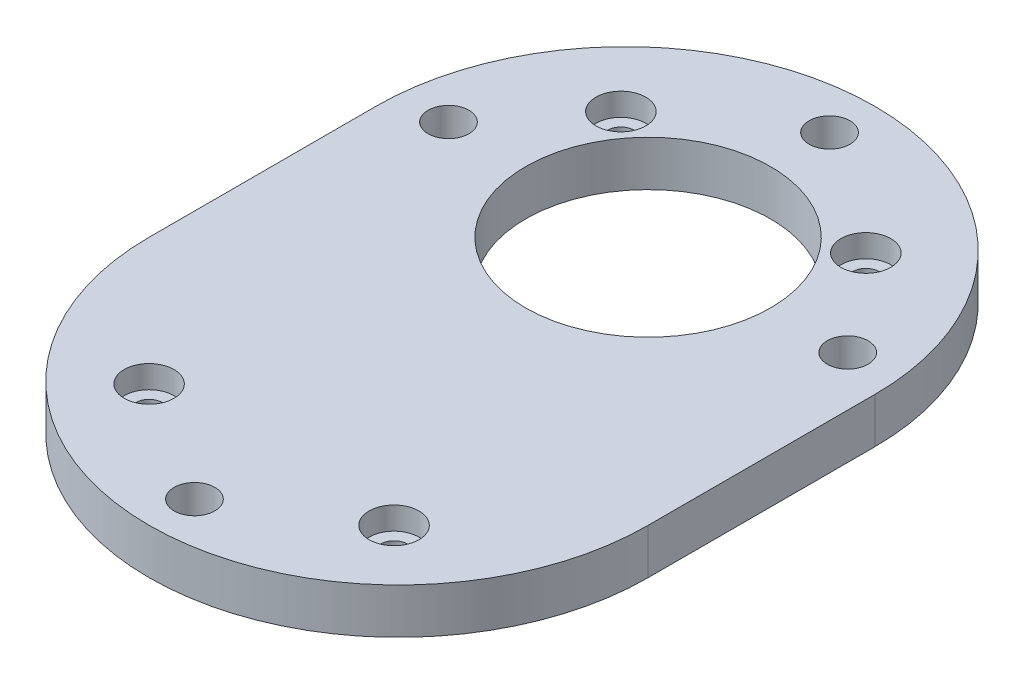
from build123d import *

# Parameters (mm, degrees)
EXTRUDE_1_DEPTH                = 5
SKETCH_2_R                     = 13.5
CUT_EXTRUDE_1_DEPTH            = 5
SKETCH_4_R                     = 2.25
CUT_EXTRUDE_2_DEPTH            = 5
HOLE_WIZARD_M2_5_1_D           = 2.9
HOLE_WIZARD_M2_5_1_CBORE_D     = 5.5
HOLE_WIZARD_M2_5_1_CBORE_DEPTH = 2.5


with BuildPart() as part:
    # 스케치1 → 보스-돌출1 (new body)
    with BuildSketch(Plane(origin=(0, 0, 0), x_dir=(1, 0, 0), z_dir=(0, 1, 0))):
        with BuildLine():
            Line((-27.5, 15), (-27.5, -10))
            ThreePointArc((-27.5, -10), (0, -37.5), (27.5, -10))
            Line((27.5, -10), (27.5, 15))
            ThreePointArc((27.5, 15), (0, 42.5), (-27.5, 15))
        make_face()
    extrude(amount=EXTRUDE_1_DEPTH)

    # 스케치2 → 컷-돌출1 (cut)
    with BuildSketch(Plane(origin=(0, 5, 0), x_dir=(1, 0, 0), z_dir=(0, 1, 0))):
        with Locations((0, 17.5)):
            Circle(SKETCH_2_R)
    extrude(amount=-CUT_EXTRUDE_1_DEPTH, mode=Mode.SUBTRACT)

    # 스케치4 → 컷-돌출2 (cut)
    with BuildSketch(Plane(origin=(0, 5, 0), x_dir=(1, 0, 0), z_dir=(0, 1, 0))):
        with Locations((0, 37.5)):
            Circle(SKETCH_4_R)
        with Locations((0, -32.5)):
            Circle(SKETCH_4_R)
        with Locations((-22, 17.5)):
            Circle(SKETCH_4_R)
        with Locations((22, 17.5)):
            Circle(SKETCH_4_R)
    extrude(amount=-CUT_EXTRUDE_2_DEPTH, mode=Mode.SUBTRACT)

    # M2.5 소켓 머리 캡 나사용 카운터보어1 (through all)
    with Locations(Plane(origin=(0, 5, 0), x_dir=(1, 0, 0), z_dir=(0, 1, 0))):
        with Locations((-13.5, 28), (13.5, 28), (13.5, -24), (-13.5, -24)):
            CounterBoreHole(HOLE_WIZARD_M2_5_1_D / 2, HOLE_WIZARD_M2_5_1_CBORE_D / 2, HOLE_WIZARD_M2_5_1_CBORE_DEPTH)


solid = part.part
